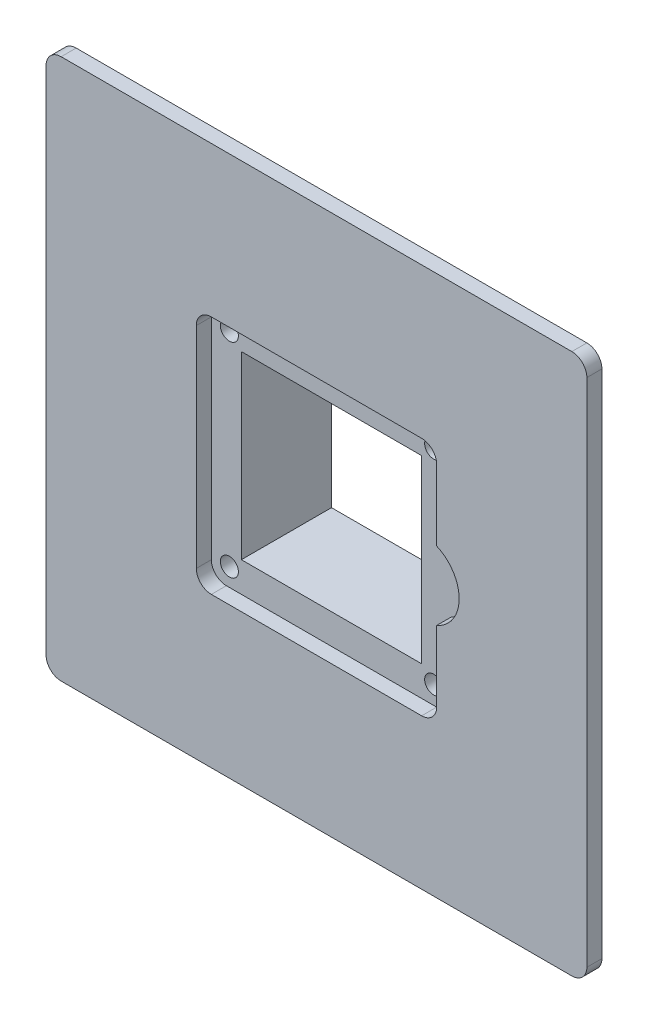
from build123d import *

# Parameters (mm, degrees)
SKETCH1_W           = 90
SKETCH1_H           = 90
BOSS_EXTRUDE1_DEPTH = 2.5
SKETCH3_W           = 50
SKETCH3_H           = 50
BOSS_EXTRUDE4_DEPTH = 15
SKETCH2_W           = 40
SKETCH2_H           = 40
CUT_EXTRUDE4_DEPTH  = 2.5
SKETCH8_R           = 1.5
CUT_EXTRUDE6_DEPTH  = 5
FILLET1_R           = 2.5
FILLET2_R           = 2.5
FILLET3_R           = 2.5
SKETCH10_R          = 6.25
CUT_EXTRUDE12_DEPTH = 2.5
SKETCH11_W          = 30
SKETCH11_H          = 30
CUT_EXTRUDE13_DEPTH = 15
SKETCH12_R          = 1.5
CUT_EXTRUDE14_DEPTH = 5
FILLET4_R           = 5
FILLET5_R           = 5


with BuildPart() as part:
    # Sketch1 → Boss-Extrude1 (new body)
    with BuildSketch(Plane.XY):
        with Locations((45, 45)):
            Rectangle(SKETCH1_W, SKETCH1_H)
    extrude(amount=BOSS_EXTRUDE1_DEPTH)

    # Sketch3 → Boss-Extrude4 (add)
    with BuildSketch(Plane(origin=(0, 0, 0), x_dir=(-1, 0, 0), z_dir=(0, 0, -1))):
        with Locations((-45, 45)):
            Rectangle(SKETCH3_W, SKETCH3_H)
    extrude(amount=BOSS_EXTRUDE4_DEPTH)

    # Sketch2 → Cut-Extrude4 (cut)
    with BuildSketch(Plane.XY.offset(2.5)):
        with Locations((45, 45)):
            Rectangle(SKETCH2_W, SKETCH2_H)
    extrude(amount=-CUT_EXTRUDE4_DEPTH, mode=Mode.SUBTRACT)

    # Sketch8 → Cut-Extrude6 (cut)
    with BuildSketch(Plane.XY):
        with Locations((62, 62)):
            Circle(SKETCH8_R)
        with Locations((62, 28)):
            Circle(SKETCH8_R)
        with Locations((28, 62)):
            Circle(SKETCH8_R)
        with Locations((28, 28)):
            Circle(SKETCH8_R)
    extrude(amount=-CUT_EXTRUDE6_DEPTH, mode=Mode.SUBTRACT)

    # Fillet1
    fillet1_edges = [part.edges().sort_by_distance(p)[0] for p in [
        (0, 90, 1.25),
        (90, 90, 1.25),
        (90, 0, 1.25),
        (0, 0, 1.25),
    ]]
    fillet(fillet1_edges, radius=FILLET1_R)

    # Fillet2
    fillet2_edges = [part.edges().sort_by_distance(p)[0] for p in [
        (25, 65, 1.25),
        (65, 65, 1.25),
    ]]
    fillet(fillet2_edges, radius=FILLET2_R)

    # Fillet3
    fillet3_edges = [part.edges().sort_by_distance(p)[0] for p in [
        (25, 25, 1.25),
        (65, 25, 1.25),
    ]]
    fillet(fillet3_edges, radius=FILLET3_R)

    # Sketch10 → Cut-Extrude12 (cut)
    with BuildSketch(Plane.XY.offset(2.5)):
        with Locations((62.5, 45)):
            Circle(SKETCH10_R)
    extrude(amount=-CUT_EXTRUDE12_DEPTH, mode=Mode.SUBTRACT)

    # Sketch11 → Cut-Extrude13 (cut)
    with BuildSketch(Plane.XY):
        with Locations((45, 45)):
            Rectangle(SKETCH11_W, SKETCH11_H)
    extrude(amount=-CUT_EXTRUDE13_DEPTH, mode=Mode.SUBTRACT)

    # Sketch12 → Cut-Extrude14 (cut)
    with BuildSketch(Plane(origin=(0, 0, -15), x_dir=(-1, 0, 0), z_dir=(0, 0, -1))):
        with Locations((-28, 28)):
            Circle(SKETCH12_R)
        with Locations((-28, 62)):
            Circle(SKETCH12_R)
        with Locations((-62, 62)):
            Circle(SKETCH12_R)
        with Locations((-62, 28)):
            Circle(SKETCH12_R)
    extrude(amount=-CUT_EXTRUDE14_DEPTH, mode=Mode.SUBTRACT)

    # Fillet4
    fillet4_edges = [part.edges().sort_by_distance(p)[0] for p in [
        (70, 70, -7.5),
        (70, 20, -7.5),
    ]]
    fillet(fillet4_edges, radius=FILLET4_R)

    # Fillet5
    fillet5_edges = [part.edges().sort_by_distance(p)[0] for p in [
        (20, 20, -7.5),
        (20, 70, -7.5),
    ]]
    fillet(fillet5_edges, radius=FILLET5_R)


solid = part.part
